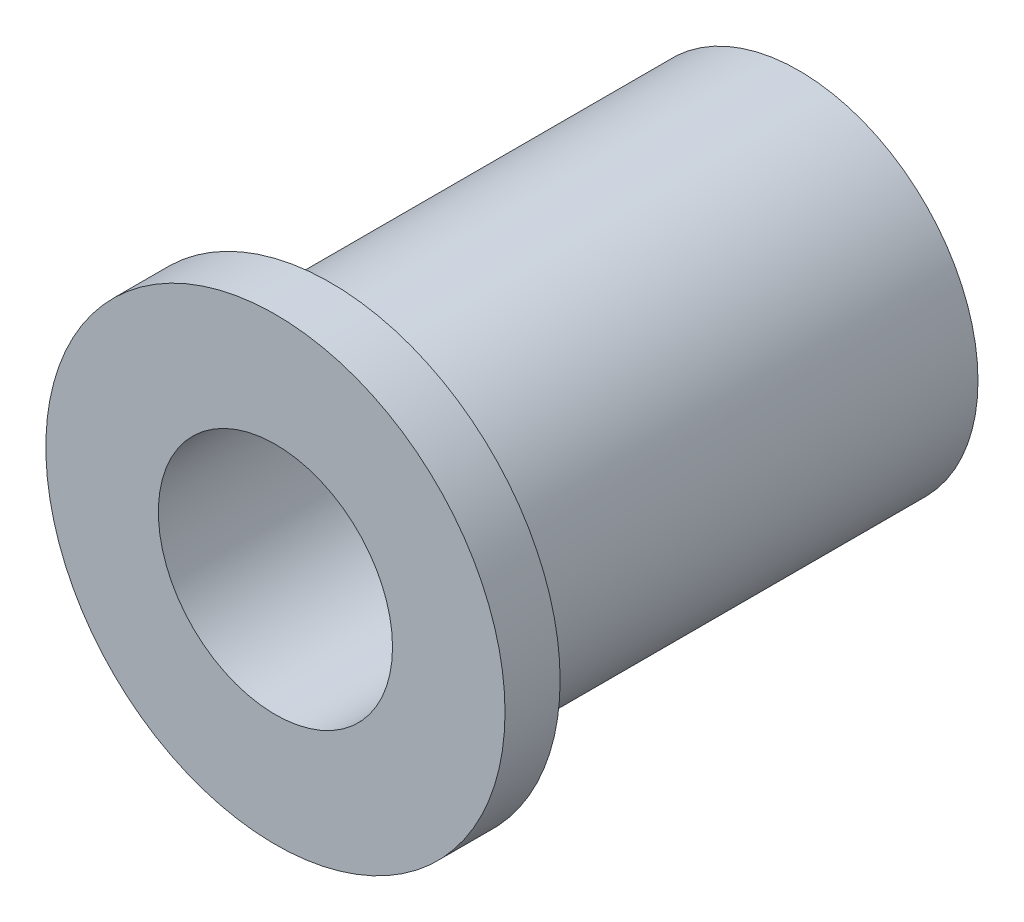
from build123d import *

# Parameters (mm, degrees)
SKETCH1_R           = 4.953
SKETCH1_R_2         = 3.2385
BOSS_EXTRUDE1_DEPTH = 14.478
SKETCH2_R           = 6.35
SKETCH2_R_2         = 3.2385
BOSS_EXTRUDE2_DEPTH = 1.524


with BuildPart() as part:
    # Sketch1 → Boss-Extrude1 (new body)
    with BuildSketch(Plane.XY):
        Circle(SKETCH1_R)
        Circle(SKETCH1_R_2, mode=Mode.SUBTRACT)
    extrude(amount=BOSS_EXTRUDE1_DEPTH)

    # Sketch2 → Boss-Extrude2 (add)
    with BuildSketch(Plane.XY.offset(14.478)):
        Circle(SKETCH2_R)
        Circle(SKETCH2_R_2, mode=Mode.SUBTRACT)
    extrude(amount=-BOSS_EXTRUDE2_DEPTH)


solid = part.part
